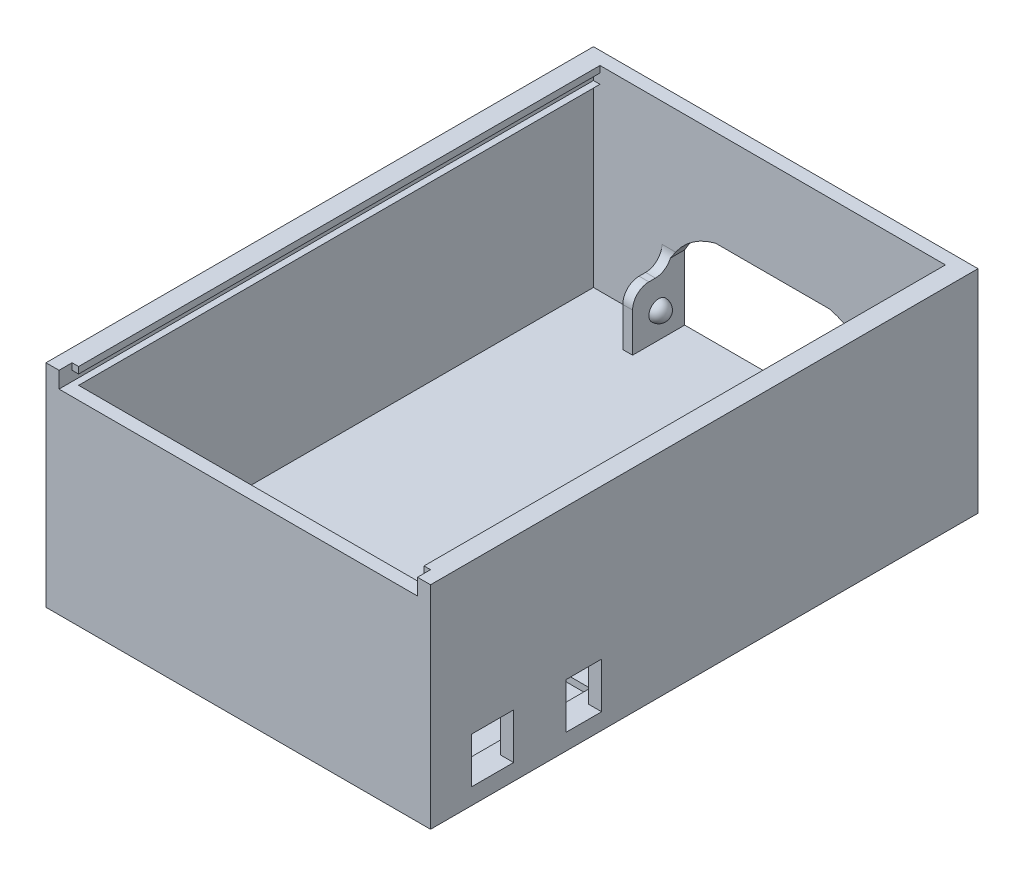
from build123d import *

# Parameters (mm, degrees)
SKETCH1_W           = 118
SKETCH1_H           = 168
BOSS_EXTRUDE1_DEPTH = 5
SKETCH2_W           = 118
SKETCH2_H           = 168
SKETCH2_W_2         = 110
SKETCH2_H_2         = 160
BOSS_EXTRUDE2_DEPTH = 60
SKETCH3_W           = 13
SKETCH3_H           = 14
SKETCH3_W_2         = 11
CUT_EXTRUDE1_DEPTH  = 10
SKETCH4_W           = 98
SKETCH4_H           = 50.5
CUT_EXTRUDE2_DEPTH  = 2
CUT_EXTRUDE3_DEPTH  = 10
SKETCH6_W           = 3
SKETCH6_H           = 17
BOSS_EXTRUDE3_DEPTH = 12
REVOLVE2_ANGLE      = 180
FILLET1_R           = 5
SKETCH10_W          = 110
SKETCH10_H          = 5
CUT_EXTRUDE4_DEPTH  = 12
SKETCH11_W          = 2
SKETCH11_H          = 2
BOSS_EXTRUDE4_DEPTH = 160


with BuildPart() as part:
    # Sketch1 → Boss-Extrude1 (new body)
    with BuildSketch(Plane(origin=(0, 0, 0), x_dir=(1, 0, 0), z_dir=(0, 1, 0))):
        with Locations((59, 84)):
            Rectangle(SKETCH1_W, SKETCH1_H)
    extrude(amount=BOSS_EXTRUDE1_DEPTH)

    # Sketch2 → Boss-Extrude2 (add)
    with BuildSketch(Plane(origin=(0, 5, 0), x_dir=(1, 0, 0), z_dir=(0, 1, 0))):
        with Locations((59, 84)):
            Rectangle(SKETCH2_W, SKETCH2_H)
        with Locations((59, 84)):
            Rectangle(SKETCH2_W_2, SKETCH2_H_2, mode=Mode.SUBTRACT)
    extrude(amount=BOSS_EXTRUDE2_DEPTH)

    # Sketch3 → Cut-Extrude1 (cut)
    with BuildSketch(Plane.ZY.offset(-114)):
        with Locations((-19, 12)):
            Rectangle(SKETCH3_W, SKETCH3_H)
        with Locations((-47, 12)):
            Rectangle(SKETCH3_W_2, SKETCH3_H)
    extrude(amount=-CUT_EXTRUDE1_DEPTH, mode=Mode.SUBTRACT)

    # Sketch4 → Cut-Extrude2 (cut)
    with BuildSketch(Plane(origin=(0, 5, 0), x_dir=(1, 0, 0), z_dir=(0, 1, 0))):
        with Locations((61, 31.75)):
            Rectangle(SKETCH4_W, SKETCH4_H)
    extrude(amount=-CUT_EXTRUDE2_DEPTH, mode=Mode.SUBTRACT)

    # Sketch5 → Cut-Extrude3 (cut)
    with BuildSketch(Plane.XY.offset(-164)):
        with BuildLine():
            Line((59, 5), (90, 5))
            Line((90, 5), (90, 25))
            ThreePointArc((90, 25), (84.369036145, 31.688760758), (76.5, 35.5))
            Line((76.5, 35.5), (41.5, 35.5))
            ThreePointArc((41.5, 35.5), (33.630963855, 31.688760758), (28, 25))
            Line((28, 25), (28, 5))
            Line((28, 5), (59, 5))
        make_face()
    extrude(amount=-CUT_EXTRUDE3_DEPTH, mode=Mode.SUBTRACT)

    # Sketch6 → Boss-Extrude3 (add)
    with BuildSketch(Plane.XY.offset(-164)):
        with Locations((26.5, 13.5)):
            Rectangle(SKETCH6_W, SKETCH6_H)
        with Locations((91.5, 13.5)):
            Rectangle(SKETCH6_W, SKETCH6_H)
    extrude(amount=BOSS_EXTRUDE3_DEPTH)

    # Sketch7 → Revolve1 (revolve)
    with BuildSketch(Plane(origin=(28, 0, 0), x_dir=(0, 0, -1), z_dir=(1, 0, 0))):
        with BuildLine():
            Line((157, 13), (163, 13))
            ThreePointArc((163, 13), (160, 10), (157, 13))
        make_face()
    revolve(axis=Axis((28, 13, -157), (0, 0, -1)))

    # Sketch9 → Revolve2 (revolve)
    with BuildSketch(Plane.ZY.offset(-90)):
        with BuildLine():
            Line((-163, 13), (-157, 13))
            ThreePointArc((-157, 13), (-160, 10), (-163, 13))
        make_face()
    revolve(axis=Axis((90, 13, -163), (0, 0, -1)), revolution_arc=REVOLVE2_ANGLE)

    # Fillet1
    fillet1_edges = [part.edges().sort_by_distance(p)[0] for p in [
        (91.5, 22, -152),
        (91.5, 22, -164),
        (26.5, 22, -164),
        (26.5, 22, -152),
    ]]
    fillet(fillet1_edges, radius=FILLET1_R)

    # Sketch10 → Cut-Extrude4 (cut)
    with BuildSketch(Plane(origin=(0, 0, -4), x_dir=(-1, 0, 0), z_dir=(0, 0, -1))):
        with Locations((-59, 62.5)):
            Rectangle(SKETCH10_W, SKETCH10_H)
    extrude(amount=-CUT_EXTRUDE4_DEPTH, mode=Mode.SUBTRACT)

    # Sketch11 → Boss-Extrude4 (add)
    with BuildSketch(Plane(origin=(0, 0, -4), x_dir=(-1, 0, 0), z_dir=(0, 0, -1))):
        Polygon((-114, 60), (-114, 58), (-112, 60), align=None)
        Polygon((-4, 60), (-4, 58), (-6, 60), align=None)
        with Locations((-113, 64)):
            Rectangle(SKETCH11_W, SKETCH11_H)
        with Locations((-5, 64)):
            Rectangle(SKETCH11_W, SKETCH11_H)
    extrude(amount=BOSS_EXTRUDE4_DEPTH)


solid = part.part
